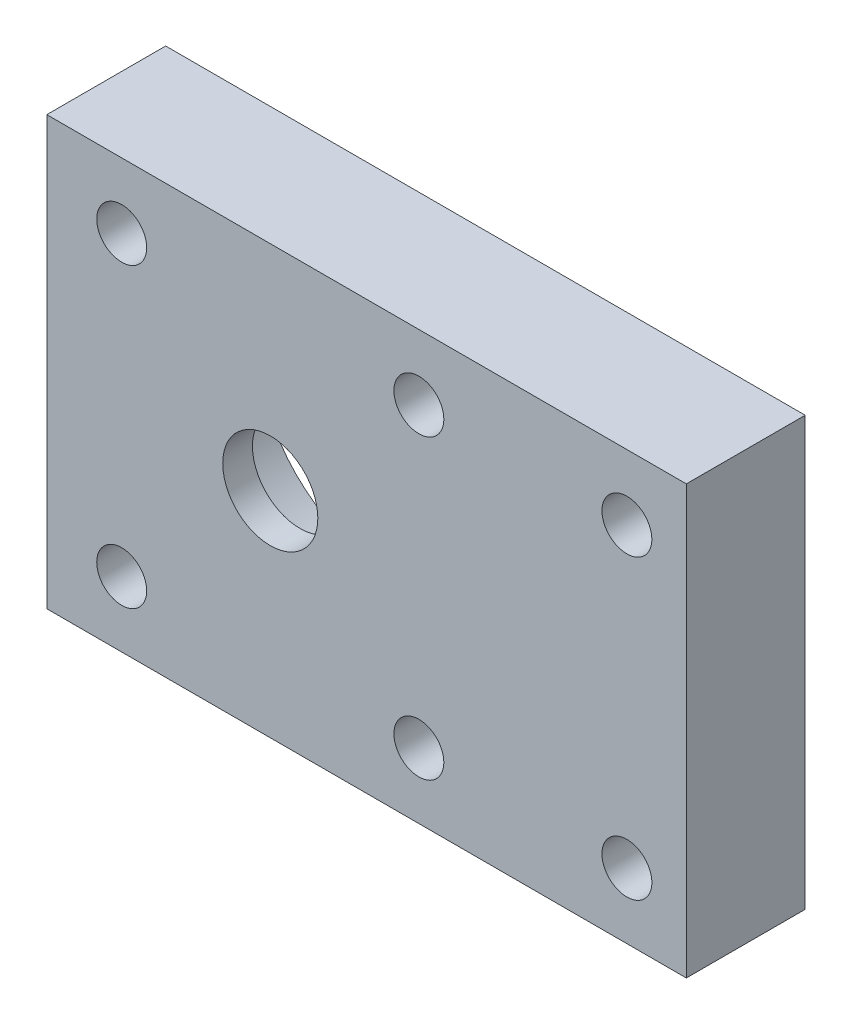
from build123d import *

# Parameters (mm, degrees)
SKETCH1_W           = 53.8
SKETCH1_H           = 40
SKETCH1_R           = 2.1
SKETCH1_R_2         = 4
BOSS_EXTRUDE1_DEPTH = 10
SKETCH2_R           = 11
CUT_EXTRUDE1_DEPTH  = 7.5
SKETCH3_W           = 53.8
SKETCH3_H           = 10
CUT_EXTRUDE2_DEPTH  = 2
SKETCH4_W           = 53.8
SKETCH4_H           = 10
CUT_EXTRUDE3_DEPTH  = 2


with BuildPart() as part:
    # Sketch1 → Boss-Extrude1 (new body)
    with BuildSketch(Plane.XY):
        with Locations((-26.9, 20)):
            Rectangle(SKETCH1_W, SKETCH1_H)
        with Locations((-22.5, 32.5)):
            Circle(SKETCH1_R, mode=Mode.SUBTRACT)
        with Locations((-47.5, 7.5)):
            Circle(SKETCH1_R, mode=Mode.SUBTRACT)
        with Locations((-47.5, 32.5)):
            Circle(SKETCH1_R, mode=Mode.SUBTRACT)
        with Locations((-22.5, 7.5)):
            Circle(SKETCH1_R, mode=Mode.SUBTRACT)
        with Locations((-5, 32.5)):
            Circle(SKETCH1_R, mode=Mode.SUBTRACT)
        with Locations((-5, 7.5)):
            Circle(SKETCH1_R, mode=Mode.SUBTRACT)
        with Locations((-35, 20)):
            Circle(SKETCH1_R_2, mode=Mode.SUBTRACT)
    extrude(amount=BOSS_EXTRUDE1_DEPTH)

    # Sketch2 → Cut-Extrude1 (cut)
    with BuildSketch(Plane(origin=(0, 0, 0), x_dir=(-1, 0, 0), z_dir=(0, 0, -1))):
        with Locations((35, 20)):
            Circle(SKETCH2_R)
    extrude(amount=-CUT_EXTRUDE1_DEPTH, mode=Mode.SUBTRACT)

    # Sketch3 → Cut-Extrude2 (cut)
    with BuildSketch(Plane.XZ):
        with Locations((-26.9, 5)):
            Rectangle(SKETCH3_W, SKETCH3_H)
    extrude(amount=-CUT_EXTRUDE2_DEPTH, mode=Mode.SUBTRACT)

    # Sketch4 → Cut-Extrude3 (cut)
    with BuildSketch(Plane(origin=(0, 40, 0), x_dir=(1, 0, 0), z_dir=(0, 1, 0))):
        with Locations((-26.9, -5)):
            Rectangle(SKETCH4_W, SKETCH4_H)
    extrude(amount=-CUT_EXTRUDE3_DEPTH, mode=Mode.SUBTRACT)


solid = part.part
